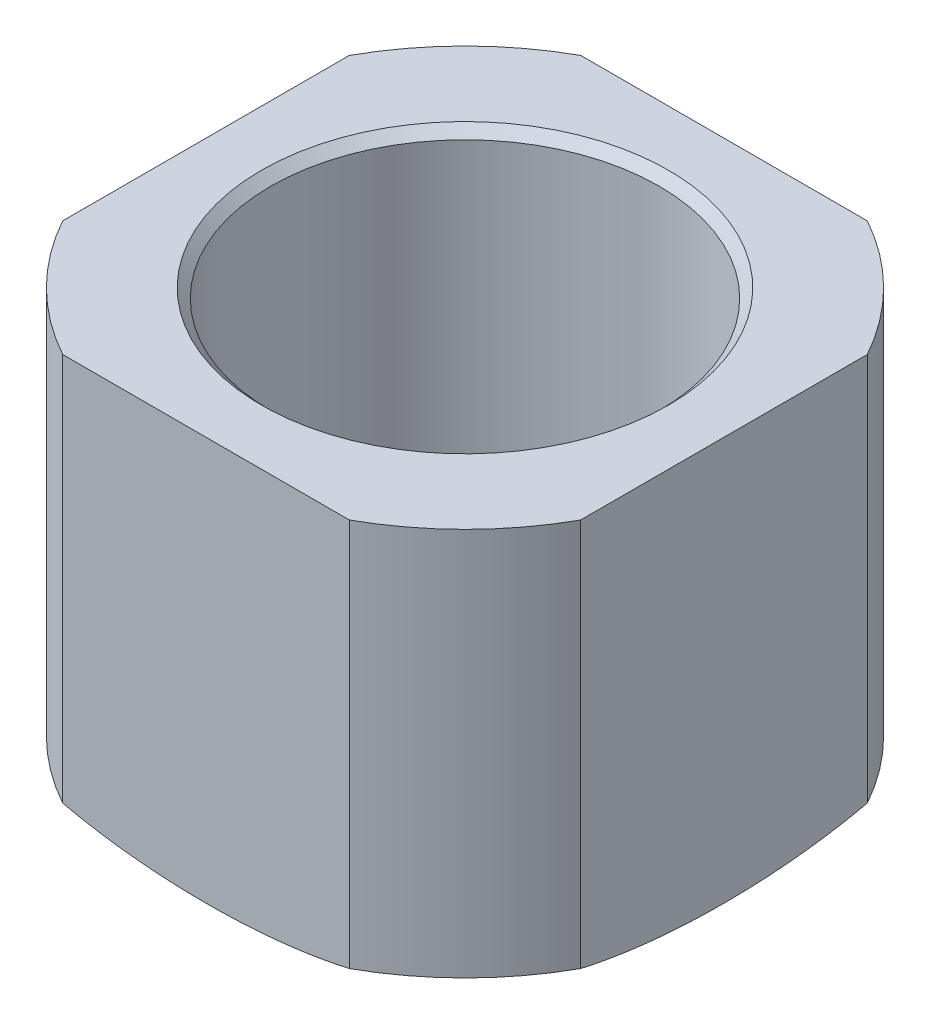
from build123d import *

# Parameters (mm, degrees)
CHAMFER1_SIZE      = 0.79375
CUT_EXTRUDE1_DEPTH = 37.5125001
CIRPATTERN1_COUNT  = 4


with BuildPart() as part:
    # Sketch1 → Revolve1 (revolve)
    with BuildSketch(Plane.XY):
        with BuildLine():
            Line((25.4, 36.5125), (16.66875, 36.5125))
            Line((16.66875, 36.5125), (16.66875, 7.361934691))
            Line((16.66875, 7.361934691), (11.1125, 3.175))
            Line((11.1125, 3.175), (11.1125, 0))
            ThreePointArc((11.1125, 0), (18.430513413, 0.803314642), (25.4, 3.175))
            Line((25.4, 3.175), (25.4, 36.5125))
        make_face()
    revolve(axis=Axis((0, 53.46364703, 0), (0, -1, 0)))

    # Chamfer1
    chamfer1_edges = [part.edges().sort_by_distance(p)[0] for p in [
        (-16.66875, 36.5125, 0),
    ]]
    chamfer(chamfer1_edges, length=CHAMFER1_SIZE)

    # Sketch8 → Cut-Extrude1 (cut, through all)
    with BuildSketch(Plane(origin=(0, 36.5125, 0), x_dir=(1, 0, 0), z_dir=(0, 1, 0))):
        with BuildLine():
            Line((-22.225, 12.296722124), (-22.225, -12.296722124))
            ThreePointArc((-22.225, -12.296722124), (-25.4, 0), (-22.225, 12.296722124))
        make_face()
    cut_extrude1 = extrude(amount=-CUT_EXTRUDE1_DEPTH, mode=Mode.SUBTRACT)

    # CirPattern1: Cut-Extrude1 ×4 about axis
    cirpattern1_axis = Axis((0, 0, 0), (0, 1, 0))
    for i in range(1, CIRPATTERN1_COUNT):
        add(cut_extrude1.rotate(cirpattern1_axis, i * 360 / CIRPATTERN1_COUNT), mode=Mode.SUBTRACT)


solid = part.part
